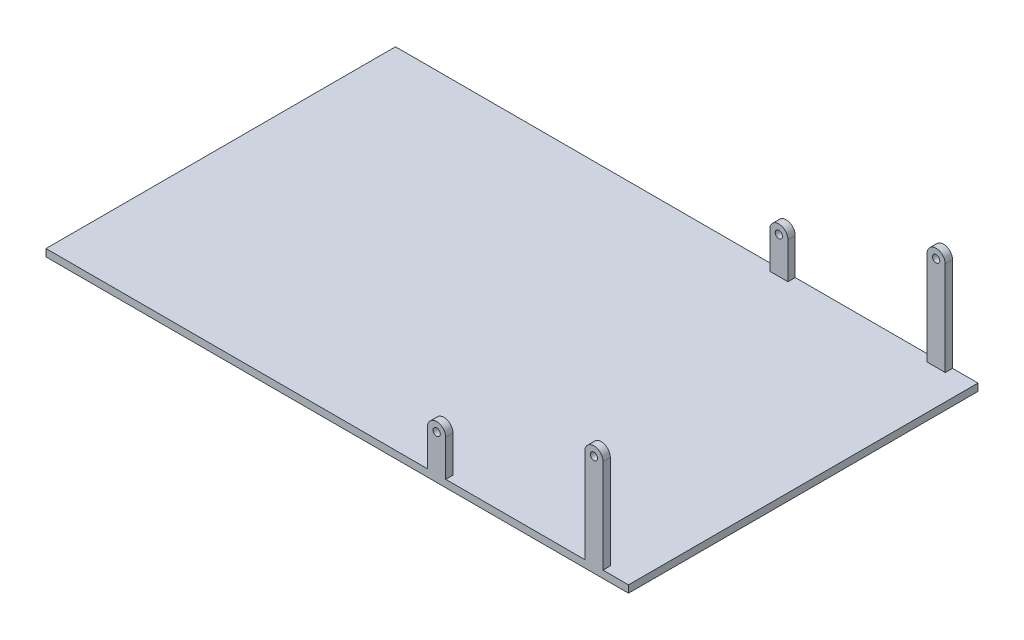
from build123d import *

# Parameters (mm, degrees)
SKETCH1_W           = 1600
SKETCH1_H           = 960
BOSS_EXTRUDE1_DEPTH = 20
SKETCH2_R           = 10
BOSS_EXTRUDE2_DEPTH = 20


with BuildPart() as part:
    # Sketch1 → Boss-Extrude1 (new body)
    with BuildSketch(Plane(origin=(0, 0, 0), x_dir=(1, 0, 0), z_dir=(0, 1, 0))):
        Rectangle(SKETCH1_W, SKETCH1_H)
    extrude(amount=-BOSS_EXTRUDE1_DEPTH)

    # Sketch2 → Boss-Extrude2 (add)
    with BuildSketch(Plane.XY.offset(480)):
        with BuildLine():
            Line((248, 0), (298, 0))
            Line((298, 0), (298, 100))
            ThreePointArc((298, 100), (273, 125), (248, 100))
            Line((248, 100), (248, 0))
        make_face()
        with Locations((273, 100)):
            Circle(SKETCH2_R, mode=Mode.SUBTRACT)
        with BuildLine():
            Line((680, 258.2), (680, 0))
            Line((680, 0), (730, 0))
            Line((730, 0), (730, 258.2))
            ThreePointArc((730, 258.2), (705, 283.2), (680, 258.2))
        make_face()
        with Locations((705, 258.2)):
            Circle(SKETCH2_R, mode=Mode.SUBTRACT)
    extrude(amount=-BOSS_EXTRUDE2_DEPTH)

    # Mirror1: part across plane


with BuildPart() as part_1:
    add(part.part)
    add(part.part.mirror(Plane.XY))


solid = part_1.part
